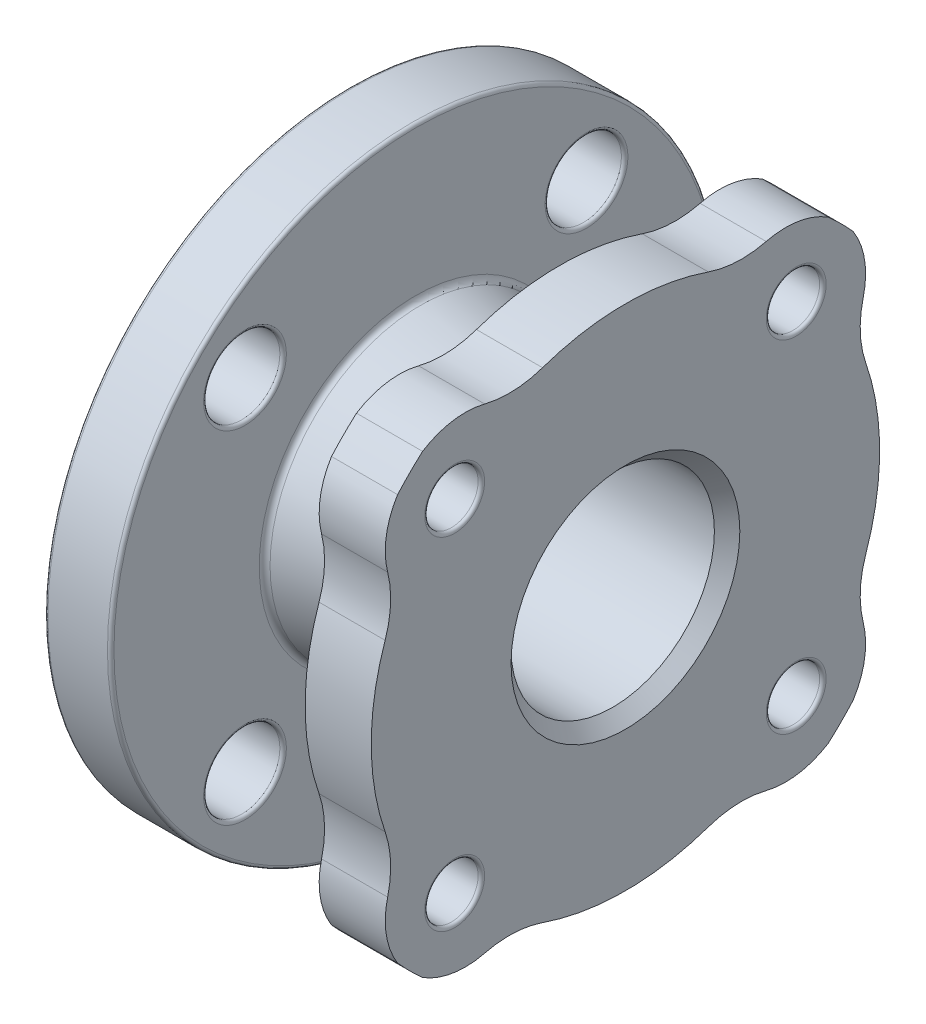
from build123d import *

# Parameters (mm, degrees)
BOSS_EXTRUDE1_START = -16.51
BOSS_EXTRUDE1_DEPTH = 16.51
CUT_EXTRUDE1_DEPTH  = 129.767290975
FILLET1_R           = 1.524
CHAMFER1_SIZE       = 3.175
CUT_EXTRUDE2_REACH  = 129.898
SKETCH4_R           = 9.525
FILLET2_R           = 0.8128


with BuildPart() as part:
    # Sketch2 → Revolve1 (revolve)
    with BuildSketch(Plane.XY):
        Polygon((-20.170588235, -25.4), (50.314411765, -25.4), (50.314411765, -55.469117647), (33.804411765, -55.469117647), (33.804411765, -47.625), (32.204211765, -46.0248), (32.204211765, -34.29), (14.754411765, -34.29), (-2.060388235, -37.864096073), (-2.060388235, -76.2), (-18.570388235, -76.2), (-18.570388235, -47.6377), (-20.170588235, -46.0375), align=None)
    revolve(axis=Axis((-79.001470588, 0, 0), (1, 0, 0)))

    # Sketch3 → Boss-Extrude1 (add)
    with BuildSketch(Plane(origin=(50.314411765, 0, 0), x_dir=(0, 0, -1), z_dir=(1, 0, 0)).offset(BOSS_EXTRUDE1_START)):
        with BuildLine():
            ThreePointArc((-59.397702762, 35.155754325), (-58.663134882, 27.887114056), (-60.027858809, 20.710049898))
            ThreePointArc((-60.027858809, 20.710049898), (-63.5, 0), (-60.027858809, -20.710049898))
            ThreePointArc((-60.027858809, -20.710049898), (-58.663134882, -27.887114056), (-59.397702762, -35.155754325))
            ThreePointArc((-59.397702762, -35.155754325), (-59.743065592, -43.167415334), (-56.911999787, -50.670151769))
            ThreePointArc((-56.911999787, -50.670151769), (-53.881536726, -53.881536726), (-50.670151769, -56.911999787))
            ThreePointArc((-50.670151769, -56.911999787), (-43.167415334, -59.743065592), (-35.155754325, -59.397702762))
            ThreePointArc((-35.155754325, -59.397702762), (-27.887114056, -58.663134882), (-20.710049898, -60.027858809))
            ThreePointArc((-20.710049898, -60.027858809), (0, -63.5), (20.710049898, -60.027858809))
            ThreePointArc((20.710049898, -60.027858809), (27.887114056, -58.663134882), (35.155754325, -59.397702762))
            ThreePointArc((35.155754325, -59.397702762), (43.167415334, -59.743065592), (50.670151769, -56.911999787))
            ThreePointArc((50.670151769, -56.911999787), (53.881536726, -53.881536726), (56.911999787, -50.670151769))
            ThreePointArc((56.911999787, -50.670151769), (59.743065592, -43.167415334), (59.397702762, -35.155754325))
            ThreePointArc((59.397702762, -35.155754325), (58.663134882, -27.887114056), (60.027858809, -20.710049898))
            ThreePointArc((60.027858809, -20.710049898), (63.5, 0), (60.027858809, 20.710049898))
            ThreePointArc((60.027858809, 20.710049898), (58.663134882, 27.887114056), (59.397702762, 35.155754325))
            ThreePointArc((59.397702762, 35.155754325), (59.743065592, 43.167415334), (56.911999787, 50.670151769))
            ThreePointArc((56.911999787, 50.670151769), (53.881536726, 53.881536726), (50.670151769, 56.911999787))
            ThreePointArc((50.670151769, 56.911999787), (43.167415334, 59.743065592), (35.155754325, 59.397702762))
            ThreePointArc((35.155754325, 59.397702762), (27.887114056, 58.663134882), (20.710049898, 60.027858809))
            ThreePointArc((20.710049898, 60.027858809), (0, 63.5), (-20.710049898, 60.027858809))
            ThreePointArc((-20.710049898, 60.027858809), (-27.887114056, 58.663134882), (-35.155754325, 59.397702762))
            ThreePointArc((-35.155754325, 59.397702762), (-43.167415334, 59.743065592), (-50.670151769, 56.911999787))
            ThreePointArc((-50.670151769, 56.911999787), (-53.881536726, 53.881536726), (-56.911999787, 50.670151769))
            ThreePointArc((-56.911999787, 50.670151769), (-59.743065592, 43.167415334), (-59.397702762, 35.155754325))
        make_face()
        with BuildLine():
            ThreePointArc((-42.195849428, 36.00462892), (-47.530898832, 47.205175703), (-35.988716575, 42.656216575))
            ThreePointArc((-35.988716575, 42.656216575), (-35.992695849, 42.425895542), (-36.00462892, 42.195849428))
            ThreePointArc((-36.00462892, 42.195849428), (0, 55.469117647), (36.00462892, 42.195849428))
            ThreePointArc((36.00462892, 42.195849428), (42.425895542, 49.319737302), (49.323716575, 42.656216575))
            ThreePointArc((49.323716575, 42.656216575), (47.205175703, 37.781534318), (42.195849428, 36.00462892))
            ThreePointArc((42.195849428, 36.00462892), (52.045122484, 19.186668242), (55.469117647, 0))
            ThreePointArc((55.469117647, 0), (52.045122484, -19.186668242), (42.195849428, -36.00462892))
            ThreePointArc((42.195849428, -36.00462892), (47.205175703, -37.781534318), (49.323716575, -42.656216575))
            ThreePointArc((49.323716575, -42.656216575), (42.425895542, -49.319737302), (36.00462892, -42.195849428))
            ThreePointArc((36.00462892, -42.195849428), (0, -55.469117647), (-36.00462892, -42.195849428))
            ThreePointArc((-36.00462892, -42.195849428), (-35.992695849, -42.425895542), (-35.988716575, -42.656216575))
            ThreePointArc((-35.988716575, -42.656216575), (-47.530898832, -47.205175703), (-42.195849428, -36.00462892))
            ThreePointArc((-42.195849428, -36.00462892), (-55.469117647, 0), (-42.195849428, 36.00462892))
        make_face(mode=Mode.SUBTRACT)
    extrude(amount=BOSS_EXTRUDE1_DEPTH)

    # Sketch3_3 → Cut-Extrude1 (cut, through all)
    with BuildSketch(Plane(origin=(50.314411765, 0, 0), x_dir=(0, 0, -1), z_dir=(1, 0, 0))):
        with BuildLine():
            ThreePointArc((-36.00462892, 42.195849428), (-39.222589235, 39.222589235), (-42.195849428, 36.00462892))
            ThreePointArc((-42.195849428, 36.00462892), (-37.941582112, 37.941582112), (-36.00462892, 42.195849428))
        make_face()
        with BuildLine():
            ThreePointArc((-36.00462892, -42.195849428), (-37.941582112, -37.941582112), (-42.195849428, -36.00462892))
            ThreePointArc((-42.195849428, -36.00462892), (-39.222589235, -39.222589235), (-36.00462892, -42.195849428))
        make_face()
        with BuildLine():
            ThreePointArc((42.195849428, 36.00462892), (39.222589235, 39.222589235), (36.00462892, 42.195849428))
            ThreePointArc((36.00462892, 42.195849428), (37.941582112, 37.941582112), (42.195849428, 36.00462892))
        make_face()
        with BuildLine():
            ThreePointArc((42.195849428, -36.00462892), (37.941582112, -37.941582112), (36.00462892, -42.195849428))
            ThreePointArc((36.00462892, -42.195849428), (39.222589235, -39.222589235), (42.195849428, -36.00462892))
        make_face()
    extrude(amount=-CUT_EXTRUDE1_DEPTH, mode=Mode.SUBTRACT)

    # Fillet1
    fillet1_edges = [part.edges().sort_by_distance(p)[0] for p in [
        (32.204211765, 34.29, 0),
        (-2.060388235, 37.864096073, 0),
    ]]
    fillet(fillet1_edges, radius=FILLET1_R)

    # Chamfer1
    chamfer1_edges = [part.edges().sort_by_distance(p)[0] for p in [
        (50.314411765, 25.4, 0),
        (-20.170588235, 25.4, 0),
    ]]
    chamfer(chamfer1_edges, length=CHAMFER1_SIZE)

    # Sketch4 → Cut-Extrude2 (cut, up to next)
    with BuildSketch(Plane.ZY.offset(18.570388235), mode=Mode.PRIVATE) as cut_extrude2_sk1:
        with Locations((-42.656216575, 42.656216575)):
            Circle(SKETCH4_R)
    cut_extrude2_tool1 = extrude(cut_extrude2_sk1.sketch, amount=-CUT_EXTRUDE2_REACH, mode=Mode.PRIVATE) & part.part
    # Sketch4 → Cut-Extrude2 (cut, up to next)
    with BuildSketch(Plane.ZY.offset(18.570388235), mode=Mode.PRIVATE) as cut_extrude2_sk2:
        with Locations((42.656216575, 42.656216575)):
            Circle(SKETCH4_R)
    cut_extrude2_tool2 = extrude(cut_extrude2_sk2.sketch, amount=-CUT_EXTRUDE2_REACH, mode=Mode.PRIVATE) & part.part
    # Sketch4 → Cut-Extrude2 (cut, up to next)
    with BuildSketch(Plane.ZY.offset(18.570388235), mode=Mode.PRIVATE) as cut_extrude2_sk3:
        with Locations((42.656216575, -42.656216575)):
            Circle(SKETCH4_R)
    cut_extrude2_tool3 = extrude(cut_extrude2_sk3.sketch, amount=-CUT_EXTRUDE2_REACH, mode=Mode.PRIVATE) & part.part
    # Sketch4 → Cut-Extrude2 (cut, up to next)
    with BuildSketch(Plane.ZY.offset(18.570388235), mode=Mode.PRIVATE) as cut_extrude2_sk4:
        with Locations((-42.656216575, -42.656216575)):
            Circle(SKETCH4_R)
    cut_extrude2_tool4 = extrude(cut_extrude2_sk4.sketch, amount=-CUT_EXTRUDE2_REACH, mode=Mode.PRIVATE) & part.part
    add(cut_extrude2_tool1.solids().sort_by_distance((-18.570388, 42.656217, -42.656217))[0], mode=Mode.SUBTRACT)
    add(cut_extrude2_tool2.solids().sort_by_distance((-18.570388, 42.656217, 42.656217))[0], mode=Mode.SUBTRACT)
    add(cut_extrude2_tool3.solids().sort_by_distance((-18.570388, -42.656217, 42.656217))[0], mode=Mode.SUBTRACT)
    add(cut_extrude2_tool4.solids().sort_by_distance((-18.570388, -42.656217, -42.656217))[0], mode=Mode.SUBTRACT)

    # Fillet2
    fillet2_edges = [part.edges().sort_by_distance(p)[0] for p in [
        (33.804411765, -49.307804231, -43.116583723),
        (50.314411765, -49.307804231, -43.116583723),
        (33.804411765, -43.116583723, 49.307804231),
        (50.314411765, -43.116583723, 49.307804231),
        (33.804411765, 42.425895542, 35.992695849),
        (50.314411765, 42.425895542, 35.992695849),
        (33.804411765, 37.781534318, -47.205175703),
        (50.314411765, 37.781534318, -47.205175703),
        (-18.570388235, -42.656216575, 33.131216575),
        (-2.060388235, -42.656216575, 33.131216575),
        (-18.570388235, -42.656216575, -52.181216575),
        (-2.060388235, -42.656216575, -52.181216575),
        (-18.570388235, 42.656216575, 33.131216575),
        (-2.060388235, 42.656216575, 33.131216575),
        (-18.570388235, 42.656216575, -52.181216575),
        (-2.060388235, 42.656216575, -52.181216575),
        (-18.570388235, 76.2, 0),
        (-2.060388235, 76.2, 0),
    ]]
    fillet(fillet2_edges, radius=FILLET2_R)


solid = part.part
